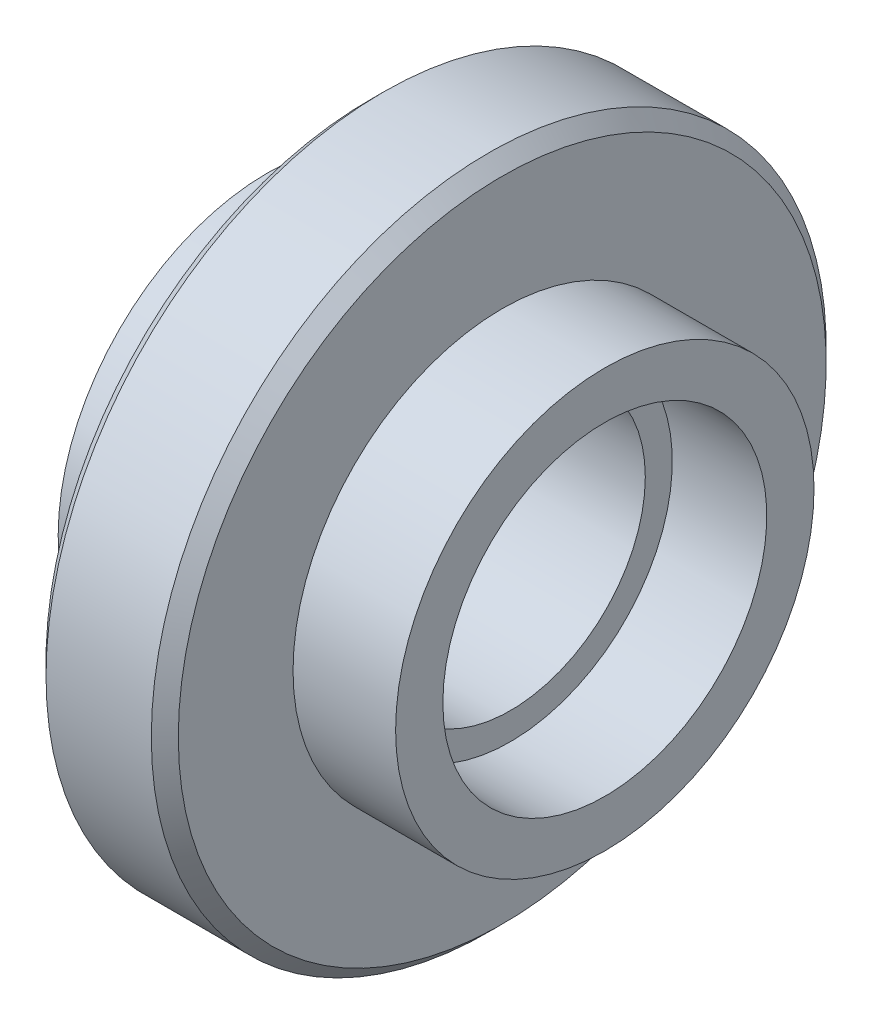
from build123d import *

# Parameters (mm, degrees)
CHAMFER_1_SIZE = 1


with BuildPart() as part:
    # Эскиз1 → Повернуть1 (revolve)
    with BuildSketch(Plane.XY, mode=Mode.PRIVATE) as revolve_1_sk:
        Polygon((-5.5, 10), (5.5, 10), (5.5, 12), (12.5, 12), (12.5, 15.5), (4.9, 15.5), (4.9, 25), (-4.9, 25), (-4.9, 15.5), (-12.5, 15.5), (-12.5, 12), (-5.5, 12), align=None)
    revolve(revolve_1_sk.sketch.rotate(Axis((-24.618848289, 0, 0), (1, 0, 0)), 90), axis=Axis((-24.618848289, 0, 0), (1, 0, 0)))  # turned: the seam where the file's is

    # Фаска1
    chamfer_1_edges = [part.edges().sort_by_distance(p)[0] for p in [
        (-4.9, 0, -25),
        (4.9, 0, -25),
    ]]
    chamfer(chamfer_1_edges, length=CHAMFER_1_SIZE)


solid = part.part
